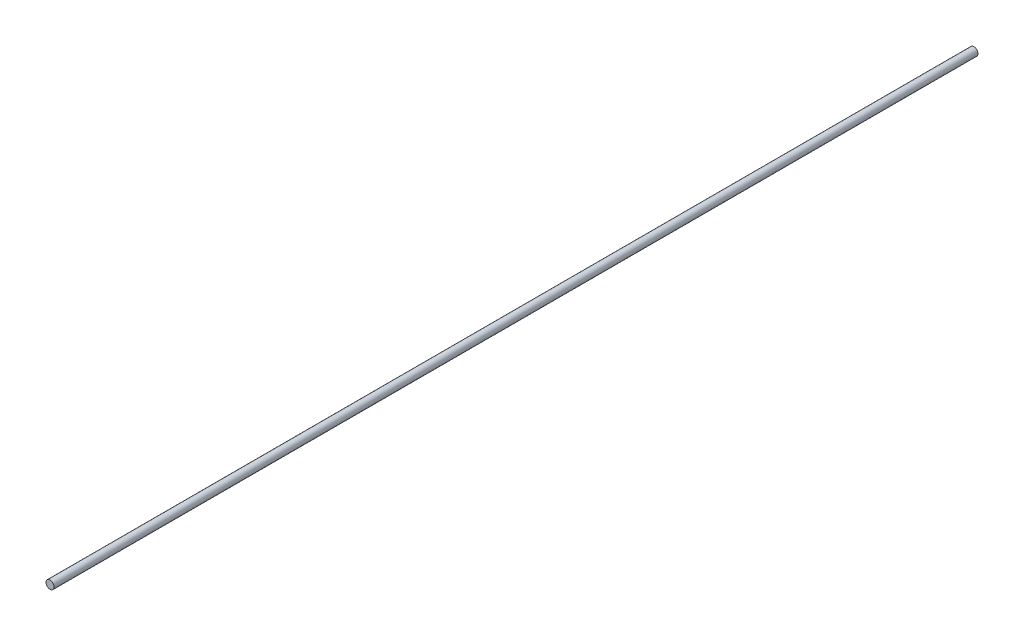
from build123d import *

# Parameters (mm, degrees)
SKETCH1_R           = 4
BOSS_EXTRUDE1_DEPTH = 914.4


with BuildPart() as part:
    # Sketch1 → Boss-Extrude1 (new body)
    with BuildSketch(Plane.XY):
        Circle(SKETCH1_R)
    extrude(amount=BOSS_EXTRUDE1_DEPTH)


solid = part.part
